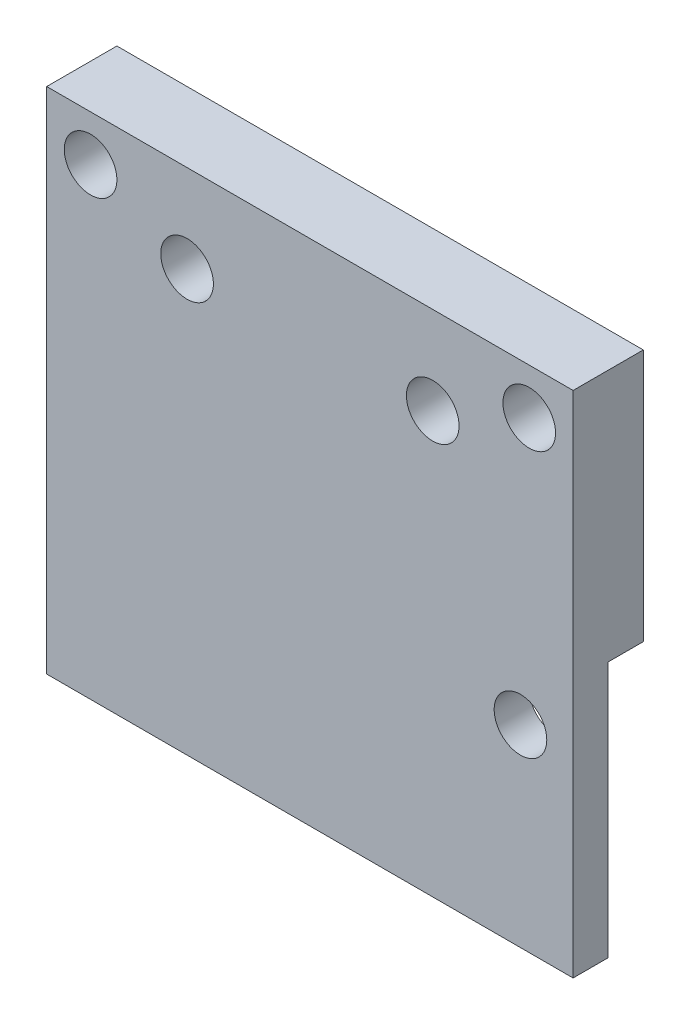
from build123d import *

# Parameters (mm, degrees)
ESBO_O3_W                = 30
ESBO_O3_H                = 29
ESBO_O3_R                = 1.5
RESSALTO_EXTRUS_O2_DEPTH = 4
ESBO_O5_W                = 30
ESBO_O5_H                = 14.6
CORTE_EXTRUS_O2_DEPTH    = 2


with BuildPart() as part:
    # Esboço3 → Ressalto-extrusão2 (new body)
    with BuildSketch(Plane.XY):
        with Locations((0, 8)):
            Rectangle(ESBO_O3_W, ESBO_O3_H)
        with Locations((-12.5, 19.897915762)):
            Circle(ESBO_O3_R, mode=Mode.SUBTRACT)
        with Locations((-7, 17.5)):
            Circle(ESBO_O3_R, mode=Mode.SUBTRACT)
        with Locations((12, 4.5)):
            Circle(ESBO_O3_R, mode=Mode.SUBTRACT)
        with Locations((7, 17.5)):
            Circle(ESBO_O3_R, mode=Mode.SUBTRACT)
        with Locations((12.5, 19.897915762)):
            Circle(ESBO_O3_R, mode=Mode.SUBTRACT)
    extrude(amount=RESSALTO_EXTRUS_O2_DEPTH)

    # Esboço5 → Corte-extrusão2 (cut)
    with BuildSketch(Plane(origin=(0, 0, 0), x_dir=(-1, 0, 0), z_dir=(0, 0, -1))):
        with Locations((0, 0.8)):
            Rectangle(ESBO_O5_W, ESBO_O5_H)
    extrude(amount=-CORTE_EXTRUS_O2_DEPTH, mode=Mode.SUBTRACT)


solid = part.part
